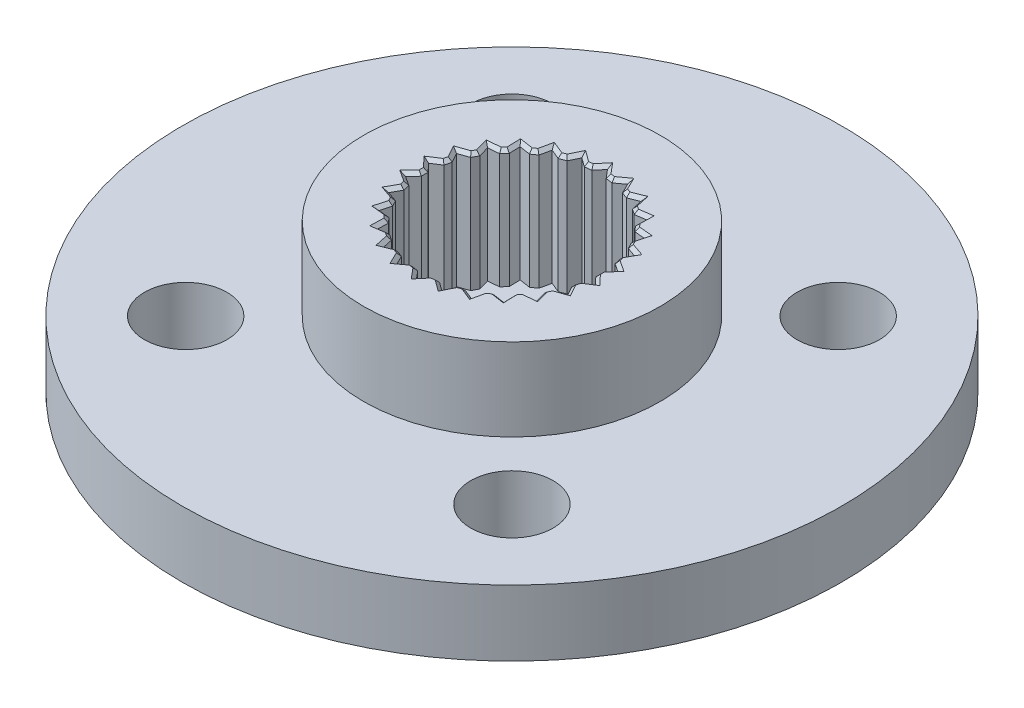
from build123d import *

# Parameters (mm, degrees)
SKETCH1_R           = 10
SKETCH1_R_2         = 1.25
SKETCH1_R_3         = 1.5
BOSS_EXTRUDE1_DEPTH = 2
SKETCH2_R           = 4.5
SKETCH2_R_2         = 1.5
BOSS_EXTRUDE2_DEPTH = 2.5
SKETCH3_R           = 2.25
CUT_EXTRUDE1_DEPTH  = 3.6
CUT_EXTRUDE2_DEPTH  = 3.6
CHAMFER1_SIZE       = 0.1


with BuildPart() as part:
    # Sketch1 → Boss-Extrude1 (new body)
    with BuildSketch(Plane(origin=(0, 0, 0), x_dir=(1, 0, 0), z_dir=(0, 1, 0))):
        Circle(SKETCH1_R)
        with Locations((-4.949747468, 4.949747468)):
            Circle(SKETCH1_R_2, mode=Mode.SUBTRACT)
        with Locations((4.949747468, 4.949747468)):
            Circle(SKETCH1_R_2, mode=Mode.SUBTRACT)
        with Locations((4.949747468, -4.949747468)):
            Circle(SKETCH1_R_2, mode=Mode.SUBTRACT)
        with Locations((-4.949747468, -4.949747468)):
            Circle(SKETCH1_R_2, mode=Mode.SUBTRACT)
        Circle(SKETCH1_R_3, mode=Mode.SUBTRACT)
    extrude(amount=BOSS_EXTRUDE1_DEPTH)

    # Sketch2 → Boss-Extrude2 (add)
    with BuildSketch(Plane(origin=(0, 2, 0), x_dir=(1, 0, 0), z_dir=(0, 1, 0))):
        Circle(SKETCH2_R)
        Circle(SKETCH2_R_2, mode=Mode.SUBTRACT)
    extrude(amount=BOSS_EXTRUDE2_DEPTH)

    # Sketch3 → Cut-Extrude1 (cut)
    with BuildSketch(Plane(origin=(0, 4.5, 0), x_dir=(1, 0, 0), z_dir=(0, 1, 0))):
        Circle(SKETCH3_R)
    extrude(amount=-CUT_EXTRUDE1_DEPTH, mode=Mode.SUBTRACT)

    # Sketch7 → Cut-Extrude2 (cut)
    with BuildSketch(Plane(origin=(0, 4.5, 0), x_dir=(1, 0, 0), z_dir=(0, 1, 0))):
        Polygon((-0.842998944, 2.512340101), (-1.034995876, 2.439525269), (-1.129082655, 2.478127827), (-1.347697199, 2.567822474), (-1.398067166, 2.336953865), (-1.419745267, 2.237593211), (-1.588737387, 2.120946373), (-1.689328372, 2.13591077), (-1.923055709, 2.17068117), (-1.916711542, 1.93446686), (-1.913981155, 1.832805537), (-2.050147256, 1.679105783), (-2.151396465, 1.669562343), (-2.386653211, 1.647387766), (-2.32396361, 1.419555673), (-2.296983416, 1.321501868), (-2.392410018, 1.139681668), (-2.488433215, 1.106185022), (-2.711547104, 1.028354172), (-2.59615536, 0.82214507), (-2.54649335, 0.733397313), (-2.595634607, 0.534023397), (-2.680851271, 0.478520248), (-2.878855735, 0.349556373), (-2.717467997, 0.176954384), (-2.648010346, 0.102670372), (-2.648010346, -0.102670372), (-2.717467997, -0.176954384), (-2.878855735, -0.349556373), (-2.680851271, -0.478520248), (-2.595634607, -0.534023397), (-2.54649335, -0.733397313), (-2.59615536, -0.82214507), (-2.711547104, -1.028354172), (-2.488433215, -1.106185022), (-2.392410018, -1.139681668), (-2.296983416, -1.321501868), (-2.32396361, -1.419555673), (-2.386653211, -1.647387766), (-2.151396465, -1.669562343), (-2.050147256, -1.679105783), (-1.913981155, -1.832805537), (-1.916711542, -1.93446686), (-1.923055709, -2.17068117), (-1.689328372, -2.13591077), (-1.588737387, -2.120946373), (-1.419745267, -2.237593211), (-1.398067166, -2.336953865), (-1.347697199, -2.567822474), (-1.129082655, -2.478127827), (-1.034995876, -2.439525269), (-0.842998944, -2.512340101), (-0.798172209, -2.603625605), (-0.694015426, -2.815731271), (-0.503218758, -2.676325101), (-0.421104166, -2.616327824), (-0.217260587, -2.641078915), (-0.151890384, -2.718984089), (0, -2.9), (0.151890384, -2.718984089), (0.217260587, -2.641078915), (0.421104166, -2.616327824), (0.503218758, -2.676325101), (0.694015426, -2.815731271), (0.798172209, -2.603625605), (0.842998944, -2.512340101), (1.034995876, -2.439525269), (1.129082655, -2.478127827), (1.347697199, -2.567822474), (1.398067166, -2.336953865), (1.419745267, -2.237593211), (1.588737387, -2.120946373), (1.689328372, -2.13591077), (1.923055709, -2.17068117), (1.916711542, -1.93446686), (1.913981155, -1.832805537), (2.050147256, -1.679105783), (2.151396465, -1.669562343), (2.386653211, -1.647387766), (2.32396361, -1.419555673), (2.296983416, -1.321501868), (2.392410018, -1.139681668), (2.488433215, -1.106185022), (2.711547104, -1.028354172), (2.59615536, -0.82214507), (2.54649335, -0.733397313), (2.595634607, -0.534023397), (2.680851271, -0.478520248), (2.878855735, -0.349556373), (2.717467997, -0.176954384), (2.648010346, -0.102670372), (2.648010346, 0.102670372), (2.717467997, 0.176954384), (2.878855735, 0.349556373), (2.680851271, 0.478520248), (2.595634607, 0.534023397), (2.54649335, 0.733397313), (2.59615536, 0.82214507), (2.711547104, 1.028354172), (2.488433215, 1.106185022), (2.392410018, 1.139681668), (2.296983416, 1.321501868), (2.32396361, 1.419555673), (2.386653211, 1.647387766), (2.151396465, 1.669562343), (2.050147256, 1.679105783), (1.913981155, 1.832805537), (1.916711542, 1.93446686), (1.923055709, 2.17068117), (1.689328372, 2.13591077), (1.588737387, 2.120946373), (1.419745267, 2.237593211), (1.398067166, 2.336953865), (1.347697199, 2.567822474), (1.129082655, 2.478127827), (1.034995876, 2.439525269), (0.842998944, 2.512340101), (0.798172209, 2.603625605), (0.694015426, 2.815731271), (0.503218758, 2.676325101), (0.421104166, 2.616327824), (0.217260587, 2.641078915), (0.151890384, 2.718984089), (0, 2.9), (-0.151890384, 2.718984089), (-0.217260587, 2.641078915), (-0.421104166, 2.616327824), (-0.503218758, 2.676325101), (-0.694015426, 2.815731271), (-0.798172209, 2.603625605), align=None)
    extrude(amount=-CUT_EXTRUDE2_DEPTH, mode=Mode.SUBTRACT)

    # Chamfer1
    chamfer1_edges = [part.edges().sort_by_distance(p)[0] for p in [
        (-1.982064206, 4.5, 1.75595566),
        (-1.918518432, 4.5, 2.001743353),
        (-1.755896548, 4.5, 2.145813771),
        (-1.504241327, 4.5, 2.179269792),
        (-1.383721233, 4.5, 2.402707843),
        (-1.191346537, 4.5, 2.503673872),
        (-0.93899741, 4.5, 2.475932685),
        (-0.768507185, 4.5, 2.664035686),
        (-0.557559796, 4.5, 2.716029547),
        (-0.319182376, 4.5, 2.62870337),
        (-0.108630293, 4.5, 2.770539458),
        (0.108630293, 4.5, 2.770539458),
        (0.319182376, 4.5, 2.62870337),
        (0.557559796, 4.5, 2.716029547),
        (0.768507185, 4.5, 2.664035686),
        (0.93899741, 4.5, 2.475932685),
        (1.191346537, 4.5, 2.503673872),
        (1.383721233, 4.5, 2.402707843),
        (1.504241327, 4.5, 2.179269792),
        (1.755896548, 4.5, 2.145813771),
        (1.918518432, 4.5, 2.001743353),
        (1.982064206, 4.5, 1.75595566),
        (2.218400233, 4.5, 1.663246774),
        (2.341818314, 4.5, 1.484444817),
        (2.344696717, 4.5, 1.230591768),
        (2.551978561, 4.5, 1.08401792),
        (2.629020227, 4.5, 0.880875743),
        (2.571063978, 4.5, 0.633710355),
        (2.737245171, 4.5, 0.441789885),
        (2.763433041, 4.5, 0.226113373),
        (2.648010346, 4.5, 0),
        (2.763433041, 4.5, -0.226113373),
        (2.737245171, 4.5, -0.441789885),
        (2.571063978, 4.5, -0.633710355),
        (2.629020227, 4.5, -0.880875743),
        (2.551978561, 4.5, -1.08401792),
        (2.344696717, 4.5, -1.230591768),
        (2.341818314, 4.5, -1.484444817),
        (2.218400233, 4.5, -1.663246774),
        (1.982064206, 4.5, -1.75595566),
        (1.918518432, 4.5, -2.001743353),
        (1.755896548, 4.5, -2.145813771),
        (1.504241327, 4.5, -2.179269792),
        (1.383721233, 4.5, -2.402707843),
        (1.191346537, 4.5, -2.503673872),
        (0.93899741, 4.5, -2.475932685),
        (0.768507185, 4.5, -2.664035686),
        (0.557559796, 4.5, -2.716029547),
        (0.319182376, 4.5, -2.62870337),
        (0.108630293, 4.5, -2.770539458),
        (-0.108630293, 4.5, -2.770539458),
        (-0.319182376, 4.5, -2.62870337),
        (-0.557559796, 4.5, -2.716029547),
        (-0.768507185, 4.5, -2.664035686),
        (-0.93899741, 4.5, -2.475932685),
        (-1.191346537, 4.5, -2.503673872),
        (-1.383721233, 4.5, -2.402707843),
        (-1.504241327, 4.5, -2.179269792),
        (-1.755896548, 4.5, -2.145813771),
        (-1.918518432, 4.5, -2.001743353),
        (-1.982064206, 4.5, -1.75595566),
        (-2.218400233, 4.5, -1.663246774),
        (-2.341818314, 4.5, -1.484444817),
        (-2.344696717, 4.5, -1.230591768),
        (-2.551978561, 4.5, -1.08401792),
        (-2.629020227, 4.5, -0.880875743),
        (-2.571063978, 4.5, -0.633710355),
        (-2.737245171, 4.5, -0.441789885),
        (-2.763433041, 4.5, -0.226113373),
        (-2.648010346, 4.5, 0),
        (-2.763433041, 4.5, 0.226113373),
        (-2.737245171, 4.5, 0.441789885),
        (-2.571063978, 4.5, 0.633710355),
        (-2.629020227, 4.5, 0.880875743),
        (-2.551978561, 4.5, 1.08401792),
        (-2.344696717, 4.5, 1.230591768),
        (-2.341818314, 4.5, 1.484444817),
        (-2.218400233, 4.5, 1.663246774),
    ]]
    chamfer(chamfer1_edges, length=CHAMFER1_SIZE)


solid = part.part
